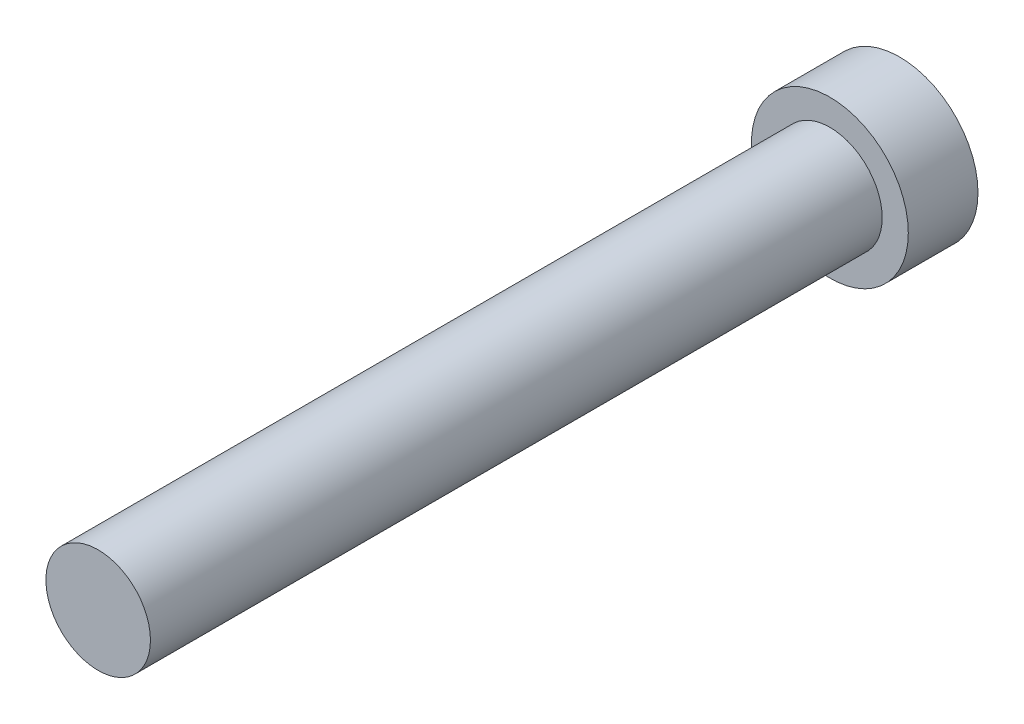
from build123d import *

# Parameters (mm, degrees)
SKETCH1_R           = 22.5
BOSS_EXTRUDE1_DEPTH = 20
SKETCH2_R           = 15
BOSS_EXTRUDE2_DEPTH = 210


with BuildPart() as part:
    # Sketch1 → Boss-Extrude1 (new body)
    with BuildSketch(Plane.XY):
        with Locations((-36.558885437, 15.141926431)):
            Circle(SKETCH1_R)
    extrude(amount=BOSS_EXTRUDE1_DEPTH)

    # Sketch2 → Boss-Extrude2 (add)
    with BuildSketch(Plane.XY.offset(20)):
        with Locations((-36.558885437, 15.141926431)):
            Circle(SKETCH2_R)
    extrude(amount=BOSS_EXTRUDE2_DEPTH)


solid = part.part
